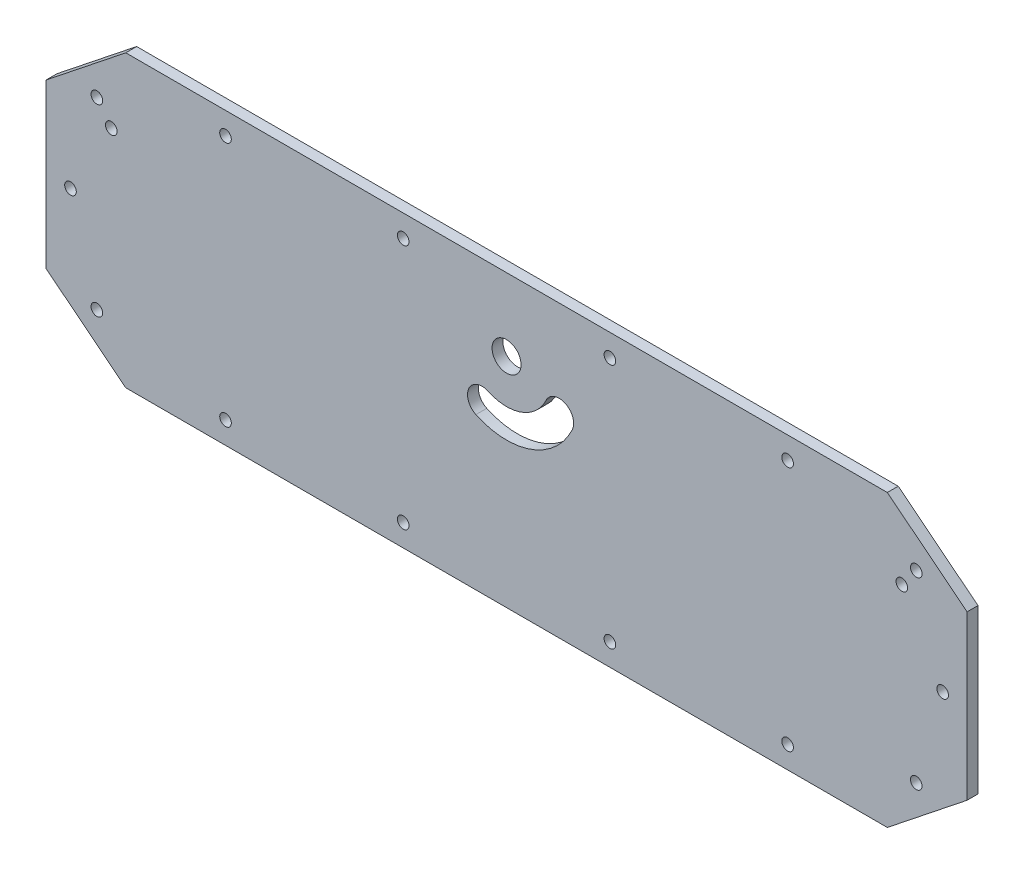
from build123d import *

# Parameters (mm, degrees)
CROQUIS1_R              = 4
CROQUIS1_R_2            = 1.6
SALIENTE_EXTRUIR1_DEPTH = 3


with BuildPart() as part:
    # Croquis1 → Saliente-Extruir1 (new body)
    with BuildSketch(Plane.XY):
        Polygon((-127, 22.5), (-105, 40), (105, 40), (127, 22.5), (127, -22.5), (105, -40), (-105, -40), (-127, -22.5), align=None)
        with Locations((0, 20)):
            Circle(CROQUIS1_R, mode=Mode.SUBTRACT)
        with Locations((112.98, 25.35)):
            Circle(CROQUIS1_R_2, mode=Mode.SUBTRACT)
        with Locations((120.25, 0)):
            Circle(CROQUIS1_R_2, mode=Mode.SUBTRACT)
        with Locations((112.98, -25.35)):
            Circle(CROQUIS1_R_2, mode=Mode.SUBTRACT)
        with Locations((77.5, -33.9)):
            Circle(CROQUIS1_R_2, mode=Mode.SUBTRACT)
        with Locations((28.5, -33.9)):
            Circle(CROQUIS1_R_2, mode=Mode.SUBTRACT)
        with Locations((-28.5, -33.9)):
            Circle(CROQUIS1_R_2, mode=Mode.SUBTRACT)
        with Locations((-77.5, -33.9)):
            Circle(CROQUIS1_R_2, mode=Mode.SUBTRACT)
        with Locations((-112.98, -25.35)):
            Circle(CROQUIS1_R_2, mode=Mode.SUBTRACT)
        with Locations((-120.25, 0)):
            Circle(CROQUIS1_R_2, mode=Mode.SUBTRACT)
        with Locations((-112.98, 25.35)):
            Circle(CROQUIS1_R_2, mode=Mode.SUBTRACT)
        with Locations((-77.5, 33.9)):
            Circle(CROQUIS1_R_2, mode=Mode.SUBTRACT)
        with Locations((-28.5, 33.9)):
            Circle(CROQUIS1_R_2, mode=Mode.SUBTRACT)
        with Locations((28.5, 33.9)):
            Circle(CROQUIS1_R_2, mode=Mode.SUBTRACT)
        with Locations((77.5, 33.9)):
            Circle(CROQUIS1_R_2, mode=Mode.SUBTRACT)
        with Locations((-109, 20)):
            Circle(CROQUIS1_R_2, mode=Mode.SUBTRACT)
        with Locations((109, 20)):
            Circle(CROQUIS1_R_2, mode=Mode.SUBTRACT)
        with BuildLine():
            ThreePointArc((-8.452365235, 1.873844259), (6.840402867, 1.206147584), (18.126155741, 11.547634765))
            ThreePointArc((18.126155741, 11.547634765), (16.19139764, 16.86333896), (10.875693444, 14.928580859))
            ThreePointArc((10.875693444, 14.928580859), (4.10424172, 8.723688551), (-5.071419141, 9.124306556))
            ThreePointArc((-5.071419141, 9.124306556), (-10.387123336, 7.189548454), (-8.452365235, 1.873844259))
        make_face(mode=Mode.SUBTRACT)
    extrude(amount=SALIENTE_EXTRUIR1_DEPTH)


solid = part.part
